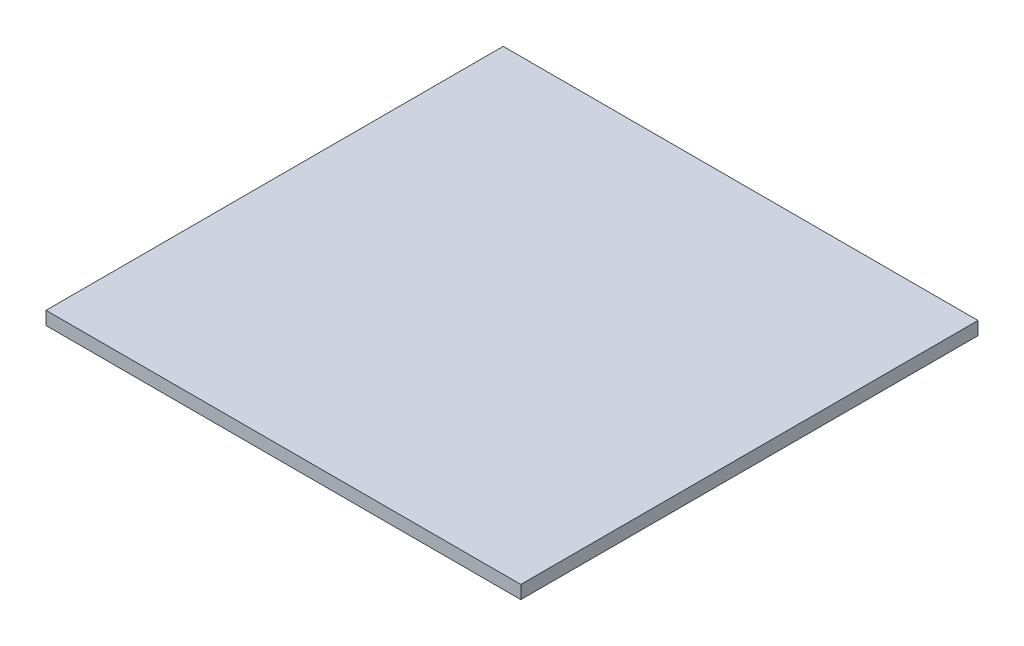
from build123d import *

# Parameters (mm, degrees)
SKETCH1_W           = 171.45
SKETCH1_H           = 165.1
BOSS_EXTRUDE1_DEPTH = 4.7625


with BuildPart() as part:
    # Sketch1 → Boss-Extrude1 (new body)
    with BuildSketch(Plane(origin=(0, 0, 0), x_dir=(1, 0, 0), z_dir=(0, 1, 0))):
        with Locations((85.725, -82.55)):
            Rectangle(SKETCH1_W, SKETCH1_H)
    extrude(amount=BOSS_EXTRUDE1_DEPTH)


solid = part.part
